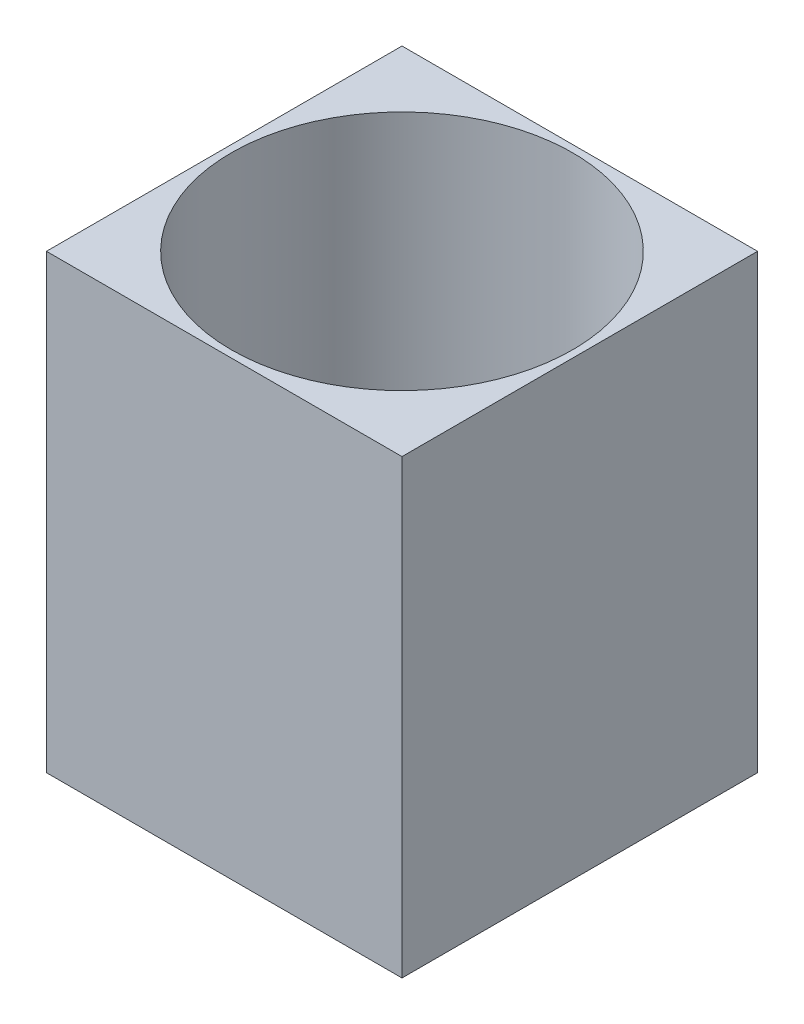
from build123d import *

# Parameters (mm, degrees)
SKETCH1_W           = 5
SKETCH1_H           = 5
SKETCH1_R           = 2.4
BOSS_EXTRUDE1_DEPTH = 6.35


with BuildPart() as part:
    # Sketch1 → Boss-Extrude1 (new body)
    with BuildSketch(Plane(origin=(0, 0, 0), x_dir=(1, 0, 0), z_dir=(0, 1, 0))):
        with Locations((2.5, 2.5)):
            Rectangle(SKETCH1_W, SKETCH1_H)
        with Locations((2.5, 2.5)):
            Circle(SKETCH1_R, mode=Mode.SUBTRACT)
    extrude(amount=BOSS_EXTRUDE1_DEPTH)


solid = part.part
